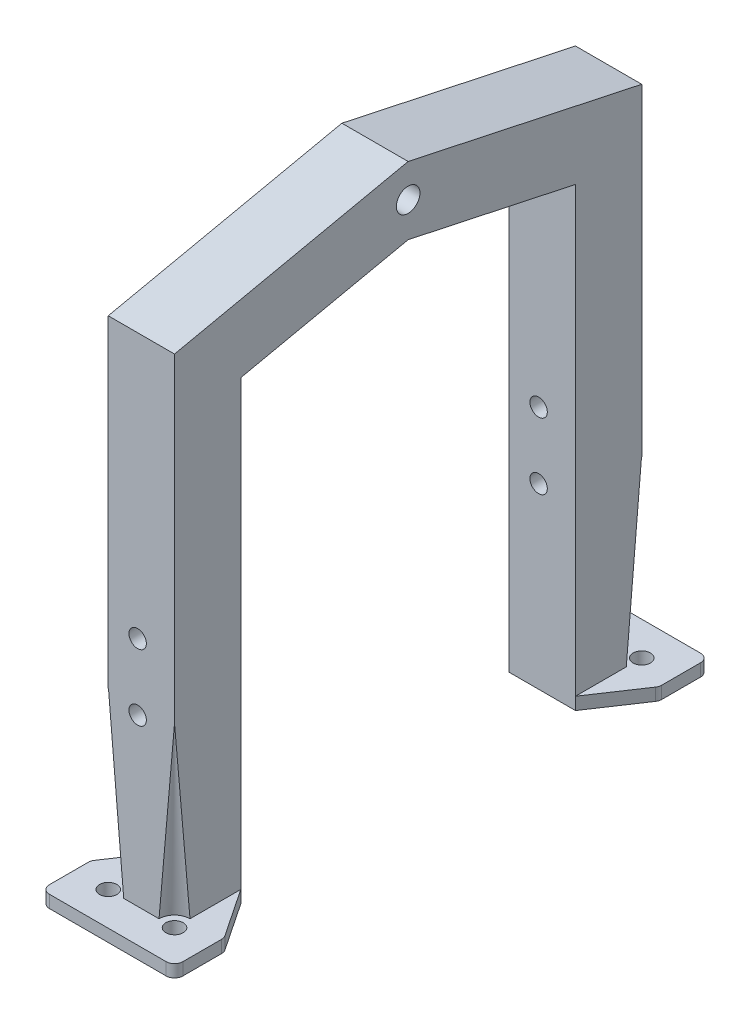
from build123d import *

# Parameters (mm, degrees)
BOSS_EXTRUDE1_DEPTH          = 8
SKETCH2_R                    = 4
CUT_EXTRUDE1_DEPTH           = 45
CUT_EXTRUDE1_TAPER           = 5
CUT_EXTRUDE1_OTHER_WAY_DEPTH = 1
SKETCH3_R                    = 2.1
BOSS_EXTRUDE2_DEPTH          = 3
FILLET1_R                    = 2
SKETCH4_R                    = 2.1
CUT_EXTRUDE2_DEPTH           = 16
FILLET1_OF_MIRROR1_R         = 2
SKETCH5_R                    = 2.85
CUT_EXTRUDE3_DEPTH           = 25.1


with BuildPart() as part:
    # Sketch1 → Boss-Extrude1 (new body, symmetric)
    with BuildSketch(Plane(origin=(0, 0, 0), x_dir=(0, 0, -1), z_dir=(1, 0, 0))):
        Polygon((-56.4, 122.940542206), (-56.4, 0), (-40.4, 0), (-40.4, 110), (0, 118.638335016), (40.4, 110), (40.4, 0), (56.4, 0), (56.4, 122.940542206), (0, 135), align=None)
    extrude(amount=BOSS_EXTRUDE1_DEPTH, both=True)

    # Sketch2 → Cut-Extrude1 (cut)
    with BuildSketch(Plane.XZ):
        with Locations((-8, -56.4)):
            Circle(SKETCH2_R)
        with Locations((8, -56.4)):
            Circle(SKETCH2_R)
    cut_extrude1 = extrude(amount=-CUT_EXTRUDE1_DEPTH, taper=CUT_EXTRUDE1_TAPER, mode=Mode.SUBTRACT)

    # Sketch2 → Cut-Extrude1 other way (cut)
    with BuildSketch(Plane.XZ):
        with Locations((-8, -56.4)):
            Circle(SKETCH2_R)
        with Locations((8, -56.4)):
            Circle(SKETCH2_R)
    extrude(amount=CUT_EXTRUDE1_OTHER_WAY_DEPTH, mode=Mode.SUBTRACT)

    # Sketch3 → Boss-Extrude2 (add)
    with BuildSketch(Plane(origin=(0, 0, 0), x_dir=(1, 0, 0), z_dir=(0, 1, 0))):
        Polygon((-8, 40.4), (8, 40.4), (16.1, 52.5), (16.1, 64.5), (-16.1, 64.5), (-16.1, 52.5), align=None)
        with Locations((-8, 56.4)):
            Circle(SKETCH3_R, mode=Mode.SUBTRACT)
        with Locations((8, 56.4)):
            Circle(SKETCH3_R, mode=Mode.SUBTRACT)
    boss_extrude2 = extrude(amount=BOSS_EXTRUDE2_DEPTH)

    # Fillet1
    fillet1_edges = [part.edges().sort_by_distance(p)[0] for p in [
        (16.1, 1.5, -52.5),
        (16.1, 1.5, -64.5),
        (-16.1, 1.5, -64.5),
        (-16.1, 1.5, -52.5),
    ]]
    fillet(fillet1_edges, radius=FILLET1_R)

    # Sketch4 → Cut-Extrude2 (cut)
    with BuildSketch(Plane(origin=(0, 0, -56.4), x_dir=(-1, 0, 0), z_dir=(0, 0, -1))):
        with Locations((0.9, 59)):
            Circle(SKETCH4_R)
        with Locations((0.9, 43)):
            Circle(SKETCH4_R)
    cut_extrude2 = extrude(amount=-CUT_EXTRUDE2_DEPTH, mode=Mode.SUBTRACT)

    # Mirror1: Cut-Extrude1, Boss-Extrude2, Cut-Extrude2 across plane
    add(cut_extrude1.mirror(Plane.XY), mode=Mode.SUBTRACT)
    add(boss_extrude2.mirror(Plane.XY))
    add(cut_extrude2.mirror(Plane.XY), mode=Mode.SUBTRACT)

    # Fillet1 of Mirror1
    fillet1_of_mirror1_edges = [part.edges().sort_by_distance(p)[0] for p in [
        (16.1, 1.5, 52.5),
        (16.1, 1.5, 64.5),
        (-16.1, 1.5, 64.5),
        (-16.1, 1.5, 52.5),
    ]]
    fillet(fillet1_of_mirror1_edges, radius=FILLET1_OF_MIRROR1_R)

    # Sketch5 → Cut-Extrude3 (cut, through all)
    with BuildSketch(Plane(origin=(8, 0, 0), x_dir=(0, 0, -1), z_dir=(1, 0, 0))):
        with Locations((0, 127)):
            Circle(SKETCH5_R)
    extrude(amount=-CUT_EXTRUDE3_DEPTH, mode=Mode.SUBTRACT)


solid = part.part
